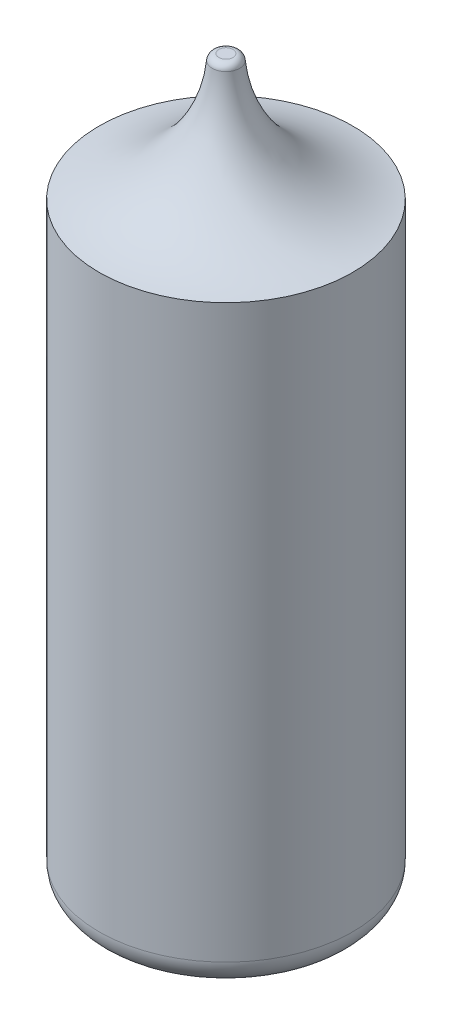
from build123d import *


with BuildPart() as part:
    # Sketch2 → Revolve1 (revolve)
    with BuildSketch(Plane(origin=(0, 0, 0), x_dir=(0, 0, -1), z_dir=(1, 0, 0))):
        with BuildLine():
            Line((0, 0), (7.55, 0))
            ThreePointArc((7.55, 0), (8.964213562, 0.585786438), (9.55, 2))
            Line((9.55, 2), (9.55, 45))
            ThreePointArc((9.55, 45), (3.714464955, 48.037260307), (1.028608879, 54.042640941))
            ThreePointArc((1.028608879, 54.042640941), (0.868572081, 54.368320832), (0.530430447, 54.5))
            Line((0.530430447, 54.5), (0, 54.5))
            Line((0, 54.5), (0, 0))
        make_face()
    revolve(axis=Axis((0, 54.5, 0), (0, -1, 0)))


solid = part.part
